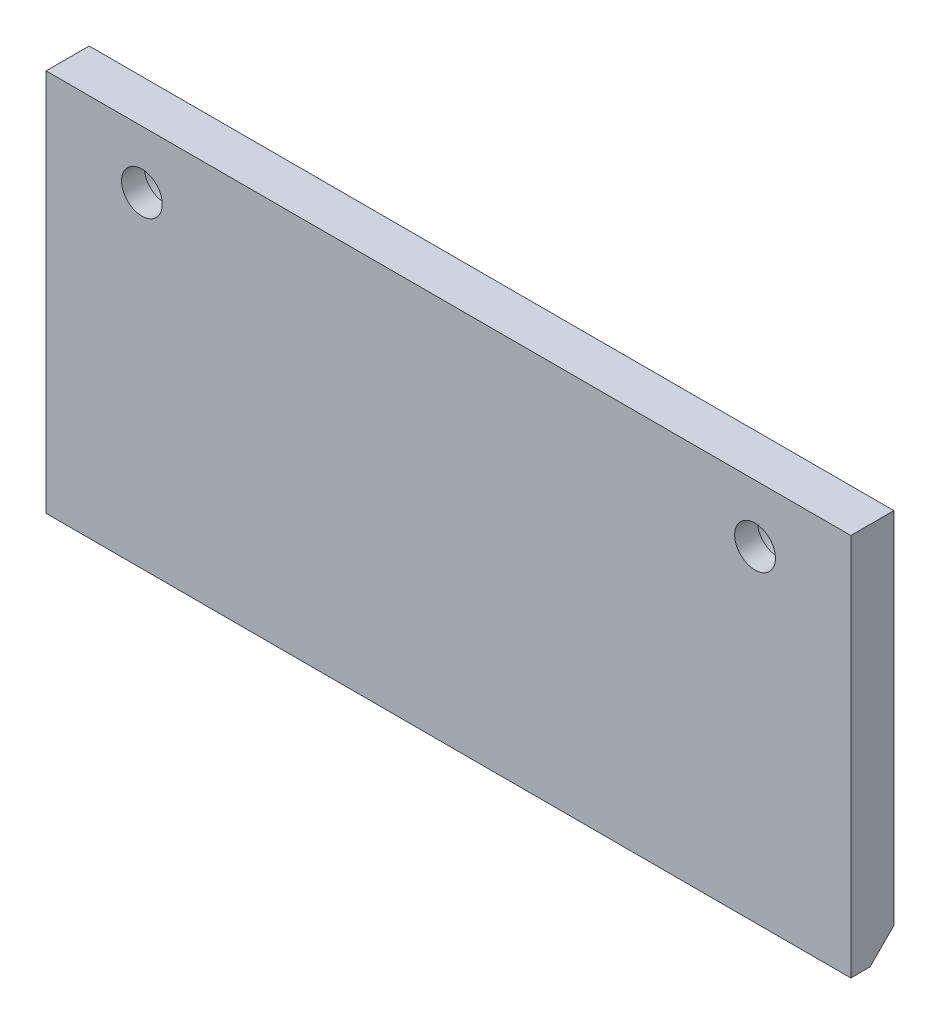
from build123d import *

# Parameters (mm, degrees)
SKETCH1_W                                        = 133.35
SKETCH1_H                                        = 63.5
BOSS_EXTRUDE1_DEPTH                              = 3.5687
CUT_EXTRUDE1_DEPTH                               = 134.35
CBORE_FOR_1_4_BUTTON_HEAD_CAP_SCREW1_D           = 6.7564
CBORE_FOR_1_4_BUTTON_HEAD_CAP_SCREW1_CBORE_D     = 11.90752
CBORE_FOR_1_4_BUTTON_HEAD_CAP_SCREW1_CBORE_DEPTH = 3.3528


with BuildPart() as part:
    # Sketch1 → Boss-Extrude1 (new body, symmetric)
    with BuildSketch(Plane.XY):
        Rectangle(SKETCH1_W, SKETCH1_H)
    extrude(amount=BOSS_EXTRUDE1_DEPTH, both=True)

    # Sketch2 → Cut-Extrude1 (cut, through all)
    with BuildSketch(Plane.ZY.offset(66.675)):
        Polygon((0.3937, -31.75), (-3.5687, -27.7876), (-3.5687, -31.75), align=None)
    extrude(amount=-CUT_EXTRUDE1_DEPTH, mode=Mode.SUBTRACT)

    # CBORE for 1/4 Button Head Cap Screw1 (through all)
    with Locations(Plane(origin=(0, 0, -3.5687), x_dir=(-1, 0, 0), z_dir=(0, 0, -1))):
        with Locations((-50.8, 22.225), (50.8, 22.225)):
            CounterBoreHole(CBORE_FOR_1_4_BUTTON_HEAD_CAP_SCREW1_D / 2, CBORE_FOR_1_4_BUTTON_HEAD_CAP_SCREW1_CBORE_D / 2, CBORE_FOR_1_4_BUTTON_HEAD_CAP_SCREW1_CBORE_DEPTH)


solid = part.part
